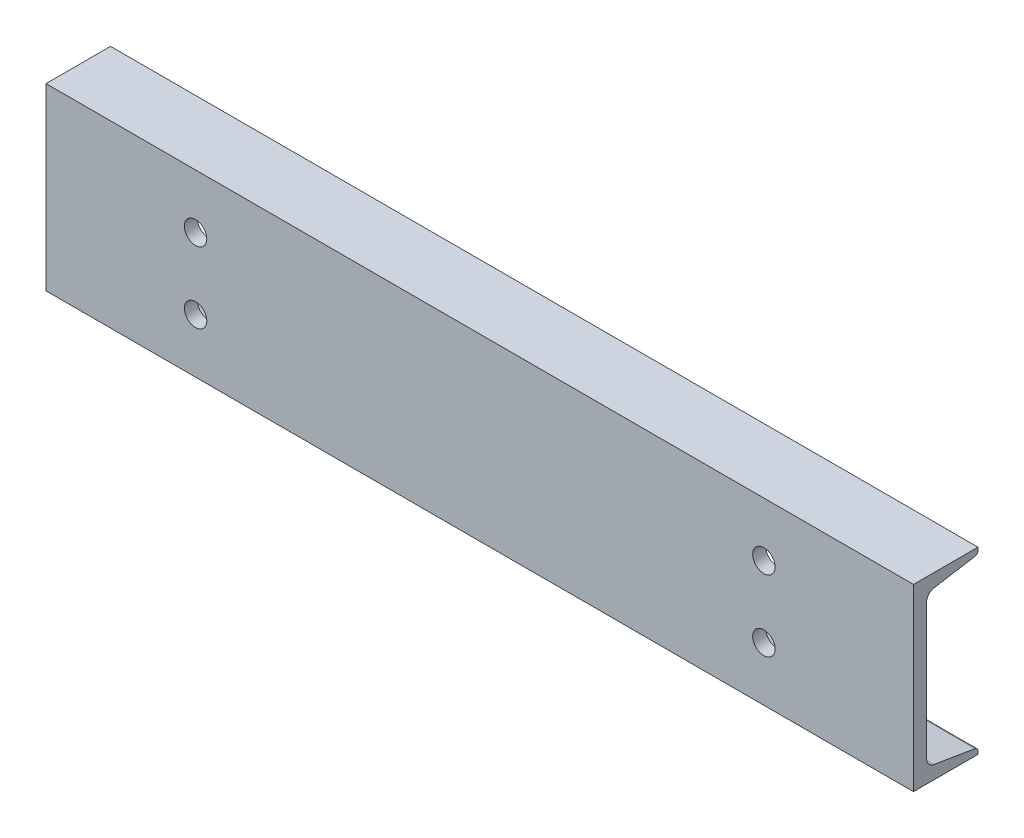
from build123d import *

# Parameters (mm, degrees)
BOSS_EXTRUDE1_DEPTH = 368.3
CUT_EXTRUDE1_REACH  = 154.4
SKETCH2_R           = 9.525
CUT_EXTRUDE2_REACH  = 56.788
SKETCH3_R           = 9.525


with BuildPart() as part:
    # Sketch1 → Boss-Extrude1 (new body, symmetric)
    with BuildSketch(Plane(origin=(0, 0, 0), x_dir=(0, 0, -1), z_dir=(1, 0, 0))):
        with BuildLine():
            Line((-27.3939, -76.2), (-27.3939, 76.2))
            Line((-27.3939, 76.2), (27.3939, 76.2))
            Line((27.3939, 76.2), (27.3939, 73.710744653))
            ThreePointArc((27.3939, 73.710744653), (26.67159656, 71.740607726), (24.84702368, 70.704221901))
            Line((24.84702368, 70.704221901), (-9.926909199, 64.908143628))
            ThreePointArc((-9.926909199, 64.908143628), (-14.488341399, 62.317179067), (-16.2941, 57.391836749))
            Line((-16.2941, 57.391836749), (-16.2941, -57.391836749))
            ThreePointArc((-16.2941, -57.391836749), (-14.488341399, -62.317179067), (-9.926909199, -64.908143628))
            Line((-9.926909199, -64.908143628), (24.84702368, -70.704221901))
            ThreePointArc((24.84702368, -70.704221901), (26.67159656, -71.740607726), (27.3939, -73.710744653))
            Line((27.3939, -73.710744653), (27.3939, -76.2))
            Line((27.3939, -76.2), (-27.3939, -76.2))
        make_face()
    extrude(amount=BOSS_EXTRUDE1_DEPTH, both=True)

    # Sketch2 → Cut-Extrude1 (cut, up to next)
    with BuildSketch(Plane.XZ.offset(76.2), mode=Mode.PRIVATE) as cut_extrude1_sk1:
        with Locations((190.5, -7.5311)):
            Circle(SKETCH2_R)
    cut_extrude1_tool1 = extrude(cut_extrude1_sk1.sketch, amount=-CUT_EXTRUDE1_REACH, mode=Mode.PRIVATE) & part.part
    add(cut_extrude1_tool1.solids().sort_by_distance((190.5, -76.2, -7.5311))[0], mode=Mode.SUBTRACT)
    # Sketch2 → Cut-Extrude1 (cut, up to next)
    with BuildSketch(Plane.XZ.offset(76.2), mode=Mode.PRIVATE) as cut_extrude1_sk2:
        with Locations((-190.5, -7.5311)):
            Circle(SKETCH2_R)
    cut_extrude1_tool2 = extrude(cut_extrude1_sk2.sketch, amount=-CUT_EXTRUDE1_REACH, mode=Mode.PRIVATE) & part.part
    add(cut_extrude1_tool2.solids().sort_by_distance((-190.5, -76.2, -7.5311))[0], mode=Mode.SUBTRACT)
    # Sketch2 → Cut-Extrude1 (cut, up to next)
    with BuildSketch(Plane.XZ.offset(76.2), mode=Mode.PRIVATE) as cut_extrude1_sk3:
        with Locations((330.2, -7.5311)):
            Circle(SKETCH2_R)
    cut_extrude1_tool3 = extrude(cut_extrude1_sk3.sketch, amount=-CUT_EXTRUDE1_REACH, mode=Mode.PRIVATE) & part.part
    add(cut_extrude1_tool3.solids().sort_by_distance((330.2, -76.2, -7.5311))[0], mode=Mode.SUBTRACT)
    # Sketch2 → Cut-Extrude1 (cut, up to next)
    with BuildSketch(Plane.XZ.offset(76.2), mode=Mode.PRIVATE) as cut_extrude1_sk4:
        with Locations((-330.2, -7.5311)):
            Circle(SKETCH2_R)
    cut_extrude1_tool4 = extrude(cut_extrude1_sk4.sketch, amount=-CUT_EXTRUDE1_REACH, mode=Mode.PRIVATE) & part.part
    add(cut_extrude1_tool4.solids().sort_by_distance((-330.2, -76.2, -7.5311))[0], mode=Mode.SUBTRACT)

    # Sketch3 → Cut-Extrude2 (cut, up to next)
    with BuildSketch(Plane.XY.offset(27.3939), mode=Mode.PRIVATE) as cut_extrude2_sk1:
        with Locations((241.3, -30.1625)):
            Circle(SKETCH3_R)
    cut_extrude2_tool1 = extrude(cut_extrude2_sk1.sketch, amount=-CUT_EXTRUDE2_REACH, mode=Mode.PRIVATE) & part.part
    add(cut_extrude2_tool1.solids().sort_by_distance((241.3, -30.1625, 27.3939))[0], mode=Mode.SUBTRACT)
    # Sketch3 → Cut-Extrude2 (cut, up to next)
    with BuildSketch(Plane.XY.offset(27.3939), mode=Mode.PRIVATE) as cut_extrude2_sk2:
        with Locations((-241.3, -30.1625)):
            Circle(SKETCH3_R)
    cut_extrude2_tool2 = extrude(cut_extrude2_sk2.sketch, amount=-CUT_EXTRUDE2_REACH, mode=Mode.PRIVATE) & part.part
    add(cut_extrude2_tool2.solids().sort_by_distance((-241.3, -30.1625, 27.3939))[0], mode=Mode.SUBTRACT)
    # Sketch3 → Cut-Extrude2 (cut, up to next)
    with BuildSketch(Plane.XY.offset(27.3939), mode=Mode.PRIVATE) as cut_extrude2_sk3:
        with Locations((-241.3, 30.1625)):
            Circle(SKETCH3_R)
    cut_extrude2_tool3 = extrude(cut_extrude2_sk3.sketch, amount=-CUT_EXTRUDE2_REACH, mode=Mode.PRIVATE) & part.part
    add(cut_extrude2_tool3.solids().sort_by_distance((-241.3, 30.1625, 27.3939))[0], mode=Mode.SUBTRACT)
    # Sketch3 → Cut-Extrude2 (cut, up to next)
    with BuildSketch(Plane.XY.offset(27.3939), mode=Mode.PRIVATE) as cut_extrude2_sk4:
        with Locations((241.3, 30.1625)):
            Circle(SKETCH3_R)
    cut_extrude2_tool4 = extrude(cut_extrude2_sk4.sketch, amount=-CUT_EXTRUDE2_REACH, mode=Mode.PRIVATE) & part.part
    add(cut_extrude2_tool4.solids().sort_by_distance((241.3, 30.1625, 27.3939))[0], mode=Mode.SUBTRACT)


solid = part.part
